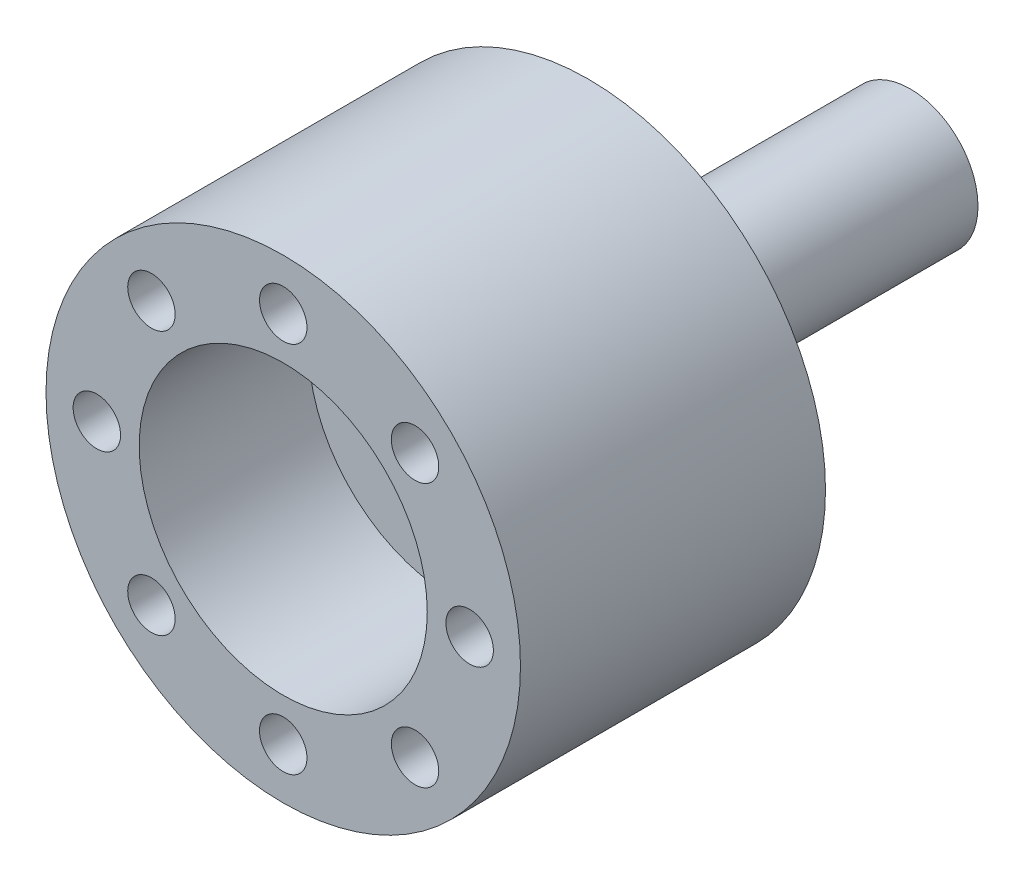
from build123d import *

# Parameters (mm, degrees)
SKETCH1_R           = 14
BOSS_EXTRUDE1_DEPTH = 18
SKETCH2_R           = 1.45
CUT_EXTRUDE1_DEPTH  = 15
SKETCH3_R           = 1.4
CUT_EXTRUDE2_DEPTH  = 6
CIRPATTERN1_COUNT   = 8
SKETCH5_R           = 2.25
CUT_EXTRUDE3_DEPTH  = 15
CIRPATTERN2_COUNT   = 8
SKETCH6_R           = 4
BOSS_EXTRUDE2_DEPTH = 19
SKETCH7_R           = 8.5
CUT_EXTRUDE4_DEPTH  = 10
SKETCH8_R           = 7.75
SKETCH8_R_2         = 4.75
CUT_EXTRUDE5_DEPTH  = 5
SKETCH10_R          = 3.25
CUT_EXTRUDE6_DEPTH  = 2.5


with BuildPart() as part:
    # Sketch1 → Boss-Extrude1 (new body)
    with BuildSketch(Plane.XY):
        Circle(SKETCH1_R)
    extrude(amount=BOSS_EXTRUDE1_DEPTH)

    # Sketch2 → Cut-Extrude1 (cut)
    with BuildSketch(Plane.XY.offset(18)):
        with Locations((4.655041669, 4.170502016)):
            Circle(SKETCH2_R)
    extrude(amount=-CUT_EXTRUDE1_DEPTH, mode=Mode.SUBTRACT)

    # Sketch3 → Cut-Extrude2 (cut)
    with BuildSketch(Plane.XY.offset(18)):
        with Locations((0, 11)):
            Circle(SKETCH3_R)
    cut_extrude2 = extrude(amount=-CUT_EXTRUDE2_DEPTH, mode=Mode.SUBTRACT)

    # CirPattern1: Cut-Extrude2 ×8 about axis
    cirpattern1_axis = Axis((0, 0, 0), (0, 0, 1))
    for i in range(1, CIRPATTERN1_COUNT):
        add(cut_extrude2.rotate(cirpattern1_axis, i * 360 / CIRPATTERN1_COUNT), mode=Mode.SUBTRACT)

    # Sketch5 → Cut-Extrude3 (cut)
    with BuildSketch(Plane(origin=(0, 0, 0), x_dir=(-1, 0, 0), z_dir=(0, 0, -1))):
        with Locations((0, 11)):
            Circle(SKETCH5_R)
    cut_extrude3 = extrude(amount=-CUT_EXTRUDE3_DEPTH, mode=Mode.SUBTRACT)

    # CirPattern2: Cut-Extrude3 ×8 about axis
    cirpattern2_axis = Axis((0, 0, 0), (0, 0, 1))
    for i in range(1, CIRPATTERN2_COUNT):
        add(cut_extrude3.rotate(cirpattern2_axis, i * 360 / CIRPATTERN2_COUNT), mode=Mode.SUBTRACT)

    # Sketch6 → Boss-Extrude2 (add)
    with BuildSketch(Plane(origin=(0, 0, 0), x_dir=(-1, 0, 0), z_dir=(0, 0, -1))):
        Circle(SKETCH6_R)
    extrude(amount=BOSS_EXTRUDE2_DEPTH)

    # Sketch7 → Cut-Extrude4 (cut)
    with BuildSketch(Plane.XY.offset(18)):
        Circle(SKETCH7_R)
    extrude(amount=-CUT_EXTRUDE4_DEPTH, mode=Mode.SUBTRACT)

    # Sketch8 → Cut-Extrude5 (cut)
    with BuildSketch(Plane(origin=(0, 0, 0), x_dir=(-1, 0, 0), z_dir=(0, 0, -1))):
        Circle(SKETCH8_R)
        Circle(SKETCH8_R_2, mode=Mode.SUBTRACT)
    extrude(amount=-CUT_EXTRUDE5_DEPTH, mode=Mode.SUBTRACT)

    # Sketch9 → Revolve1 (revolve)
    with BuildSketch(Plane(origin=(0, 0, 0), x_dir=(1, 0, 0), z_dir=(0, 1, 0))):
        Polygon((4, 1.55754099), (4.75, 0), (4, 0), align=None)
    revolve(axis=Axis((0, 0, 18), (0, 0, -1)))

    # Sketch10 → Cut-Extrude6 (cut)
    with BuildSketch(Plane(origin=(0, 0, -19), x_dir=(-1, 0, 0), z_dir=(0, 0, -1))):
        Circle(SKETCH10_R)
    extrude(amount=-CUT_EXTRUDE6_DEPTH, mode=Mode.SUBTRACT)


solid = part.part
